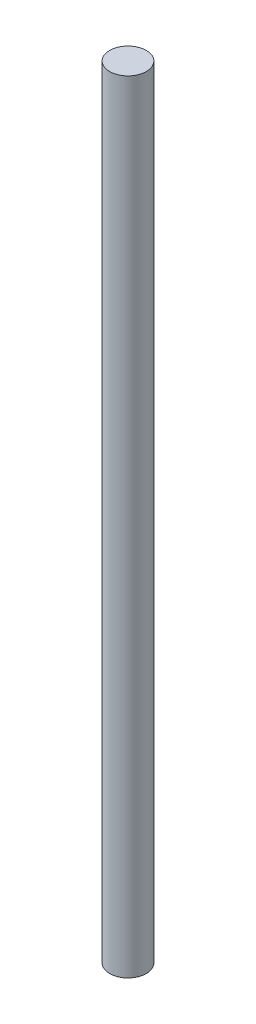
from build123d import *

# Parameters (mm, degrees)
SKETCH1_R           = 4.7625
BOSS_EXTRUDE1_DEPTH = 203.2


with BuildPart() as part:
    # Sketch1 → Boss-Extrude1 (new body)
    with BuildSketch(Plane(origin=(0, 0, 0), x_dir=(1, 0, 0), z_dir=(0, 1, 0))):
        Circle(SKETCH1_R)
    extrude(amount=BOSS_EXTRUDE1_DEPTH)


solid = part.part
